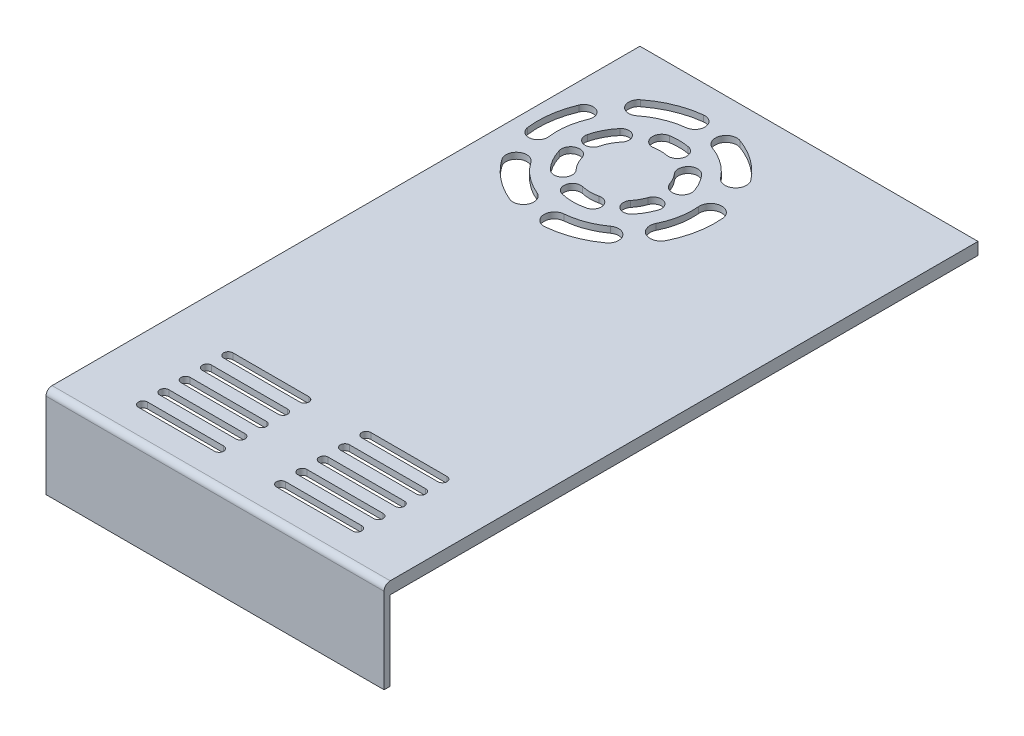
from build123d import *

# Parameters (mm, degrees)
SKETCH1_W           = 111
SKETCH1_H           = 195
BOSS_EXTRUDE3_DEPTH = 30
SKETCH12_W          = 107
SKETCH12_H          = 191
CUT_EXTRUDE14_DEPTH = 28
SKETCH13_W          = 193
SKETCH13_H          = 26
CUT_EXTRUDE15_DEPTH = 112
CUT_EXTRUDE18_DEPTH = 28
CUT_EXTRUDE20_DEPTH = 28
FILLET1_R           = 2


with BuildPart() as part:
    # Sketch1 → Boss-Extrude3 (new body)
    with BuildSketch(Plane(origin=(0, 0, 0), x_dir=(1, 0, 0), z_dir=(0, 1, 0))):
        with Locations((55.5, 97.5)):
            Rectangle(SKETCH1_W, SKETCH1_H)
    extrude(amount=BOSS_EXTRUDE3_DEPTH)

    # Sketch12 → Cut-Extrude14 (cut)
    with BuildSketch(Plane.XZ):
        with Locations((55.5, -97.5)):
            Rectangle(SKETCH12_W, SKETCH12_H)
    extrude(amount=-CUT_EXTRUDE14_DEPTH, mode=Mode.SUBTRACT)

    # Sketch13 → Cut-Extrude15 (cut, through all)
    with BuildSketch(Plane(origin=(111, 0, 0), x_dir=(0, 0, -1), z_dir=(1, 0, 0))):
        with Locations((98.5, 13)):
            Rectangle(SKETCH13_W, SKETCH13_H)
    extrude(amount=-CUT_EXTRUDE15_DEPTH, mode=Mode.SUBTRACT)

    # Sketch14 → Cut-Extrude18 (cut)
    with BuildSketch(Plane(origin=(0, 30, 0), x_dir=(1, 0, 0), z_dir=(0, 1, 0))):
        with BuildLine():
            Line((20.333, 10), (45.333, 10))
            ThreePointArc((45.333, 10), (46.833, 11.5), (45.333, 13))
            Line((45.333, 13), (20.333, 13))
            ThreePointArc((20.333, 13), (18.833, 11.5), (20.333, 10))
        make_face()
        with BuildLine():
            Line((65.663, 10), (90.663, 10))
            ThreePointArc((90.663, 10), (92.163, 11.5), (90.663, 13))
            Line((90.663, 13), (65.663, 13))
            ThreePointArc((65.663, 13), (64.163, 11.5), (65.663, 10))
        make_face()
        with BuildLine():
            Line((45.333, 17), (20.333, 17))
            ThreePointArc((20.333, 17), (18.833, 18.5), (20.333, 20))
            Line((20.333, 20), (45.333, 20))
            ThreePointArc((45.333, 20), (46.833, 18.5), (45.333, 17))
        make_face()
        with BuildLine():
            Line((20.333, 24), (45.333, 24))
            ThreePointArc((45.333, 24), (46.833, 25.5), (45.333, 27))
            Line((45.333, 27), (20.333, 27))
            ThreePointArc((20.333, 27), (18.833, 25.5), (20.333, 24))
        make_face()
        with BuildLine():
            Line((45.333, 31), (20.333, 31))
            ThreePointArc((20.333, 31), (18.833, 32.5), (20.333, 34))
            Line((20.333, 34), (45.333, 34))
            ThreePointArc((45.333, 34), (46.833, 32.5), (45.333, 31))
        make_face()
        with BuildLine():
            Line((45.333, 38), (20.333, 38))
            ThreePointArc((20.333, 38), (18.833, 39.5), (20.333, 41))
            Line((20.333, 41), (45.333, 41))
            ThreePointArc((45.333, 41), (46.833, 39.5), (45.333, 38))
        make_face()
        with BuildLine():
            Line((65.663, 17), (90.663, 17))
            ThreePointArc((90.663, 17), (92.163, 18.5), (90.663, 20))
            Line((90.663, 20), (65.663, 20))
            ThreePointArc((65.663, 20), (64.163, 18.5), (65.663, 17))
        make_face()
        with BuildLine():
            Line((65.663, 24), (90.663, 24))
            ThreePointArc((90.663, 24), (92.163, 25.5), (90.663, 27))
            Line((90.663, 27), (65.663, 27))
            ThreePointArc((65.663, 27), (64.163, 25.5), (65.663, 24))
        make_face()
        with BuildLine():
            Line((65.663, 31), (90.663, 31))
            ThreePointArc((90.663, 31), (92.163, 32.5), (90.663, 34))
            Line((90.663, 34), (65.663, 34))
            ThreePointArc((65.663, 34), (64.163, 32.5), (65.663, 31))
        make_face()
        with BuildLine():
            Line((65.663, 38), (90.663, 38))
            ThreePointArc((90.663, 38), (92.163, 39.5), (90.663, 41))
            Line((90.663, 41), (65.663, 41))
            ThreePointArc((65.663, 41), (64.163, 39.5), (65.663, 38))
        make_face()
    extrude(amount=-CUT_EXTRUDE18_DEPTH, mode=Mode.SUBTRACT)

    # Sketch15 → Cut-Extrude20 (cut)
    with BuildSketch(Plane(origin=(0, 30, 0), x_dir=(1, 0, 0), z_dir=(0, 1, 0))):
        with BuildLine():
            ThreePointArc((6.696274737, 168.245524968), (4.712292683, 160.988985093), (4.67541183, 153.466206648))
            ThreePointArc((4.67541183, 153.466206648), (8.09565845, 150.815515518), (10.74634958, 154.235762137))
            ThreePointArc((10.74634958, 154.235762137), (10.775393211, 160.159941785), (12.337776869, 165.874458854))
            ThreePointArc((12.337776869, 165.874458854), (10.70255886, 169.880742977), (6.696274737, 168.245524968))
        make_face()
        with BuildLine():
            ThreePointArc((30.042379036, 185.905642269), (22.234806909, 183.911498962), (15.277571507, 179.845583861))
            ThreePointArc((15.277571507, 179.845583861), (14.739300825, 175.27028306), (19.314601626, 174.732012377))
            ThreePointArc((19.314601626, 174.732012377), (24.708589586, 177.884341691), (30.761848907, 179.430413423))
            ThreePointArc((30.761848907, 179.430413423), (33.639728395, 183.027762782), (30.042379036, 185.905642269))
        make_face()
        with BuildLine():
            ThreePointArc((9.491647445, 140.178899737), (15.120081319, 134.248905718), (22.173648967, 130.11474554))
            ThreePointArc((22.173648967, 130.11474554), (26.634282912, 131.979280924), (24.769747528, 136.439914869))
            ThreePointArc((24.769747528, 136.439914869), (19.370249085, 139.604610035), (15.061689013, 144.144014074))
            ThreePointArc((15.061689013, 144.144014074), (10.294111061, 144.94647769), (9.491647445, 140.178899737))
        make_face()
        with BuildLine():
            ThreePointArc((56.310614137, 175.121225777), (50.432963372, 180.790251606), (43.218248225, 184.615499013))
            ThreePointArc((43.218248225, 184.615499013), (38.682523617, 182.492393878), (40.805628753, 177.95666927))
            ThreePointArc((40.805628753, 177.95666927), (46.275147004, 175.056726572), (50.731028834, 170.75900454))
            ThreePointArc((50.731028834, 170.75900454), (55.701932104, 170.150322507), (56.310614137, 175.121225777))
        make_face()
        with BuildLine():
            ThreePointArc((59.586594576, 144.047302408), (62.128106042, 151.638527757), (62.527114252, 159.633949903))
            ThreePointArc((62.527114252, 159.633949903), (58.568776784, 162.958953376), (55.24377331, 159.000615908))
            ThreePointArc((55.24377331, 159.000615908), (54.944008323, 152.99385325), (53.034633698, 147.290753636))
            ThreePointArc((53.034633698, 147.290753636), (54.688888523, 142.393047582), (59.586594576, 144.047302408))
        make_face()
        with BuildLine():
            ThreePointArc((35.768008384, 128.065909487), (43.426937588, 129.793958929), (50.34619431, 133.504651297))
            ThreePointArc((50.34619431, 133.504651297), (51.101165333, 138.243900564), (46.361916066, 138.998871587))
            ThreePointArc((46.361916066, 138.998871587), (41.05466641, 136.152674144), (35.180068745, 134.827215331))
            ThreePointArc((35.180068745, 134.827215331), (32.093385643, 131.15259259), (35.768008384, 128.065909487))
        make_face()
        with BuildLine():
            ThreePointArc((16.441661235, 152.073186373), (17.981802443, 148.454567611), (20.289670934, 145.270202728))
            ThreePointArc((20.289670934, 145.270202728), (24.525226929, 145.075748549), (24.719681108, 149.311304544))
            ThreePointArc((24.719681108, 149.311304544), (23.201014452, 151.406739699), (22.187542017, 153.787930688))
            ThreePointArc((22.187542017, 153.787930688), (18.457229469, 155.803498921), (16.441661235, 152.073186373))
        make_face()
        with BuildLine():
            ThreePointArc((29.27435513, 140.205739876), (33.244380925, 139.745216), (37.21440672, 140.205739876))
            ThreePointArc((37.21440672, 140.205739876), (39.303217461, 143.579049176), (35.929908161, 145.667859918))
            ThreePointArc((35.929908161, 145.667859918), (33.244380925, 145.356338161), (30.558853689, 145.667859918))
            ThreePointArc((30.558853689, 145.667859918), (27.185544389, 143.579049176), (29.27435513, 140.205739876))
        make_face()
        with BuildLine():
            ThreePointArc((46.62439771, 146.108244738), (48.343223739, 148.626148349), (49.593608613, 151.406569032))
            ThreePointArc((49.593608613, 151.406569032), (47.885475932, 154.933944656), (44.358100308, 153.225811975))
            ThreePointArc((44.358100308, 153.225811975), (43.508125809, 151.335764577), (42.339718927, 149.624168488))
            ThreePointArc((42.339718927, 149.624168488), (42.724096443, 145.723867222), (46.62439771, 146.108244738))
        make_face()
        with BuildLine():
            ThreePointArc((49.972810261, 162.900447104), (48.635358132, 165.848165567), (46.783719502, 168.503209204))
            ThreePointArc((46.783719502, 168.503209204), (42.312959082, 168.883687171), (41.932481115, 164.412926751))
            ThreePointArc((41.932481115, 164.412926751), (43.120664854, 162.709203559), (43.978898661, 160.817672951))
            ThreePointArc((43.978898661, 160.817672951), (48.017241537, 158.862104227), (49.972810261, 162.900447104))
        make_face()
        with BuildLine():
            ThreePointArc((20.111654536, 168.296978183), (17.884918862, 164.974641199), (16.482333682, 161.229106577))
            ThreePointArc((16.482333682, 161.229106577), (18.47726406, 157.924889924), (21.781480713, 159.919820302))
            ThreePointArc((21.781480713, 159.919820302), (22.740653165, 162.48124308), (24.263429498, 164.753257755))
            ThreePointArc((24.263429498, 164.753257755), (23.959402231, 168.601005449), (20.111654536, 168.296978183))
        make_face()
        with BuildLine():
            ThreePointArc((36.492341368, 174.366325724), (33.369121981, 174.668500564), (30.241929234, 174.410674085))
            ThreePointArc((30.241929234, 174.410674085), (27.762102428, 170.891007932), (31.281768581, 168.411181126))
            ThreePointArc((31.281768581, 168.411181126), (33.3259204, 168.579714539), (35.367474954, 168.382191937))
            ThreePointArc((35.367474954, 168.382191937), (38.921975054, 170.811825623), (36.492341368, 174.366325724))
        make_face()
    extrude(amount=-CUT_EXTRUDE20_DEPTH, mode=Mode.SUBTRACT)

    # Fillet1
    fillet1_edges = [part.edges().sort_by_distance(p)[0] for p in [
        (55.5, 30, 0),
    ]]
    fillet(fillet1_edges, radius=FILLET1_R)


solid = part.part
